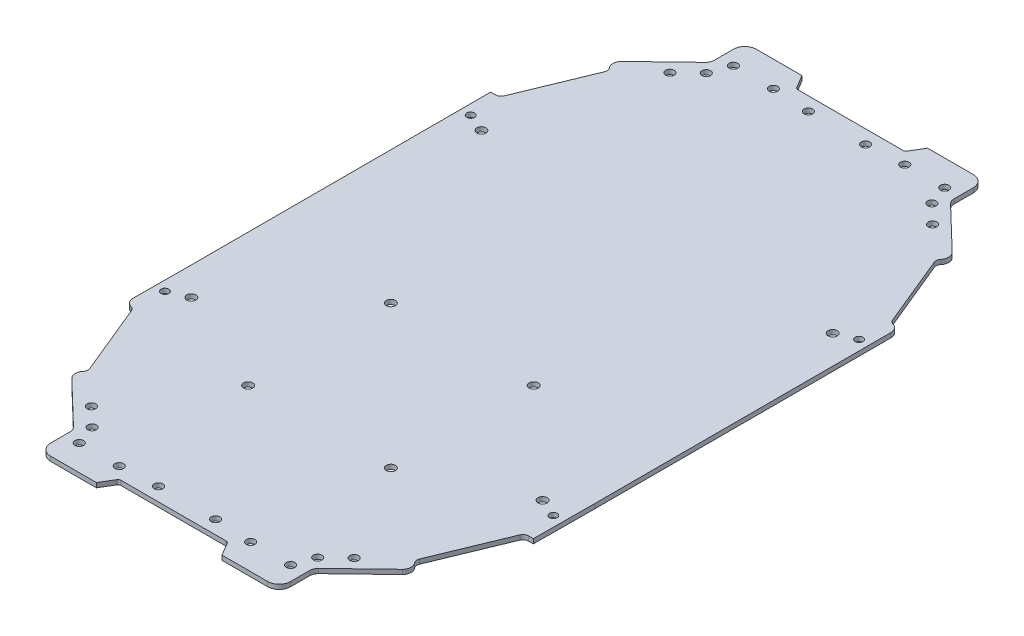
from build123d import *

# Parameters (mm, degrees)
SKETCH1_R        = 1.5
SKETCH1_R_2      = 1.600010398
SKETCH1_R_3      = 1.6
SKETCH1_R_4      = 1.35
EXTRUSION1_DEPTH = 1.6
FILLET1_R        = 1
FILLET2_R        = 4
FILLET3_R        = 3
FILLET4_R        = 3
FILLET5_R        = 2
FILLET6_R        = 2
FILLET7_R        = 3
FILLET8_R        = 3
FILLET9_R        = 2
FILLET10_R       = 2
FILLET11_R       = 3


with BuildPart() as part:
    # Sketch1 → Extrusion1 (new body)
    with BuildSketch(Plane(origin=(0, 0, 0), x_dir=(-1, 0, 0), z_dir=(0, 1, 0))):
        Polygon((59.775158519, 259.059874387), (56.775158519, 264.05987395), (36.775158519, 264.05987395), (36.775158519, 252.05987395), (18.755330752, 234.731117294), (21.527931817, 231.847944851), (10.275158581, 204.559863083), (7.271137723, 204.559863083), (7.157131709, 183.059873956), (7.157131709, 76.612413837), (10.15713177, 76.612413837), (21.409905007, 49.324332069), (18.637303942, 46.441159626), (36.657131709, 29.11240297), (36.657131709, 17.11240297), (56.657131709, 17.11240297), (59.657131709, 22.112402533), (78.657131709, 22.112402533), (97.657131709, 22.112402533), (100.657131709, 17.11240297), (120.657131709, 17.11240297), (120.657131709, 29.11240297), (138.676959475, 46.441159626), (135.90435841, 49.324332069), (147.157131647, 76.612413837), (150.157131709, 76.612413837), (150.157131709, 183.059873956), (150.275158519, 204.559863083), (147.275158457, 204.559863083), (136.022385221, 231.847944851), (138.794986286, 234.731117294), (120.775158519, 252.05987395), (120.775158519, 264.05987395), (100.775158519, 264.05987395), (97.775158519, 259.059874387), (78.657131709, 259.059874387), align=None)
        with Locations((55.657131647, 26.112401639)):
            Circle(SKETCH1_R, mode=Mode.SUBTRACT)
        with Locations((39.157131647, 33.112413837)):
            Circle(SKETCH1_R, mode=Mode.SUBTRACT)
        with Locations((53.657131709, 208.059873956)):
            Circle(SKETCH1_R_2, mode=Mode.SUBTRACT)
        with Locations((53.657131709, 158.059873956)):
            Circle(SKETCH1_R_2, mode=Mode.SUBTRACT)
        with Locations((17.157131647, 89.862401639)):
            Circle(SKETCH1_R_3, mode=Mode.SUBTRACT)
        with Locations((103.657131709, 158.059873956)):
            Circle(SKETCH1_R_2, mode=Mode.SUBTRACT)
        with Locations((41.775158457, 255.059863083)):
            Circle(SKETCH1_R, mode=Mode.SUBTRACT)
        with Locations((39.275158457, 248.059863083)):
            Circle(SKETCH1_R, mode=Mode.SUBTRACT)
        with Locations((10.775158457, 194.05987528)):
            Circle(SKETCH1_R_4, mode=Mode.SUBTRACT)
        with Locations((88.65713177, 26.862413837)):
            Circle(SKETCH1_R, mode=Mode.SUBTRACT)
        with Locations((115.65713177, 26.112413837)):
            Circle(SKETCH1_R, mode=Mode.SUBTRACT)
        with Locations((118.15713177, 33.112413837)):
            Circle(SKETCH1_R, mode=Mode.SUBTRACT)
        with Locations((140.15713177, 89.862401639)):
            Circle(SKETCH1_R_3, mode=Mode.SUBTRACT)
        with Locations((115.775158581, 255.059863083)):
            Circle(SKETCH1_R, mode=Mode.SUBTRACT)
        with Locations((88.775158581, 254.309863083)):
            Circle(SKETCH1_R, mode=Mode.SUBTRACT)
        with Locations((140.275158581, 191.30987528)):
            Circle(SKETCH1_R_3, mode=Mode.SUBTRACT)
        with Locations((146.775158581, 194.05987528)):
            Circle(SKETCH1_R_4, mode=Mode.SUBTRACT)
        with Locations((101.775158581, 255.05987528)):
            Circle(SKETCH1_R, mode=Mode.SUBTRACT)
        with Locations((118.275158581, 248.059863083)):
            Circle(SKETCH1_R, mode=Mode.SUBTRACT)
        with Locations((146.65713177, 87.112401639)):
            Circle(SKETCH1_R_4, mode=Mode.SUBTRACT)
        with Locations((101.65713177, 26.112401639)):
            Circle(SKETCH1_R, mode=Mode.SUBTRACT)
        with Locations((17.275158457, 191.30987528)):
            Circle(SKETCH1_R_3, mode=Mode.SUBTRACT)
        with Locations((55.775158457, 255.05987528)):
            Circle(SKETCH1_R, mode=Mode.SUBTRACT)
        with Locations((68.775158457, 254.309863083)):
            Circle(SKETCH1_R, mode=Mode.SUBTRACT)
        with Locations((10.657131647, 87.112401639)):
            Circle(SKETCH1_R_4, mode=Mode.SUBTRACT)
        with Locations((68.657131647, 26.862413837)):
            Circle(SKETCH1_R, mode=Mode.SUBTRACT)
        with Locations((41.657131647, 26.112413837)):
            Circle(SKETCH1_R, mode=Mode.SUBTRACT)
        with Locations((32.657131647, 39.362413837)):
            Circle(SKETCH1_R, mode=Mode.SUBTRACT)
        with Locations((124.775158581, 241.809863083)):
            Circle(SKETCH1_R, mode=Mode.SUBTRACT)
        with Locations((32.775158457, 241.809863083)):
            Circle(SKETCH1_R, mode=Mode.SUBTRACT)
        with Locations((103.657131709, 208.059873956)):
            Circle(SKETCH1_R_2, mode=Mode.SUBTRACT)
        with Locations((124.65713177, 39.362413837)):
            Circle(SKETCH1_R, mode=Mode.SUBTRACT)
    extrude(amount=EXTRUSION1_DEPTH)

    # Fillet1
    fillet1_edges = [part.edges().sort_by_distance(p)[0] for p in [
        (-97.775158519, 0.8, 259.059874387),
        (-97.657131709, 0.8, 22.112402533),
        (-59.657131709, 0.8, 22.112402533),
        (-59.775158519, 0.8, 259.059874387),
    ]]
    fillet(fillet1_edges, radius=FILLET1_R)

    # Fillet2
    fillet2_edges = [part.edges().sort_by_distance(p)[0] for p in [
        (-120.775158519, 0.8, 264.05987395),
        (-120.657131709, 0.8, 17.11240297),
        (-36.657131709, 0.8, 17.11240297),
        (-36.775158519, 0.8, 264.05987395),
    ]]
    fillet(fillet2_edges, radius=FILLET2_R)

    # Fillet3
    fillet3_edges = [part.edges().sort_by_distance(p)[0] for p in [
        (-120.775158519, 0.8, 252.05987395),
        (-120.657131709, 0.8, 29.11240297),
        (-36.657131709, 0.8, 29.11240297),
        (-36.775158519, 0.8, 252.05987395),
    ]]
    fillet(fillet3_edges, radius=FILLET3_R)

    # Fillet4
    fillet4_edges = [part.edges().sort_by_distance(p)[0] for p in [
        (-138.794986286, 0.8, 234.731117294),
    ]]
    fillet(fillet4_edges, radius=FILLET4_R)

    # Fillet5
    fillet5_edges = [part.edges().sort_by_distance(p)[0] for p in [
        (-136.022385221, 0.8, 231.847944851),
    ]]
    fillet(fillet5_edges, radius=FILLET5_R)

    # Fillet6
    fillet6_edges = [part.edges().sort_by_distance(p)[0] for p in [
        (-21.527931817, 0.8, 231.847944851),
    ]]
    fillet(fillet6_edges, radius=FILLET6_R)

    # Fillet7
    fillet7_edges = [part.edges().sort_by_distance(p)[0] for p in [
        (-18.755330752, 0.8, 234.731117294),
    ]]
    fillet(fillet7_edges, radius=FILLET7_R)

    # Fillet8
    fillet8_edges = [part.edges().sort_by_distance(p)[0] for p in [
        (-138.676959475, 0.8, 46.441159626),
        (-18.637303942, 0.8, 46.441159626),
    ]]
    fillet(fillet8_edges, radius=FILLET8_R)

    # Fillet9
    fillet9_edges = [part.edges().sort_by_distance(p)[0] for p in [
        (-21.409905007, 0.8, 49.324332069),
        (-135.90435841, 0.8, 49.324332069),
    ]]
    fillet(fillet9_edges, radius=FILLET9_R)

    # Fillet10
    fillet10_edges = [part.edges().sort_by_distance(p)[0] for p in [
        (-147.275158457, 0.8, 204.559863083),
        (-147.157131647, 0.8, 76.612413837),
        (-10.15713177, 0.8, 76.612413837),
        (-10.275158581, 0.8, 204.559863083),
    ]]
    fillet(fillet10_edges, radius=FILLET10_R)

    # Fillet11
    fillet11_edges = [part.edges().sort_by_distance(p)[0] for p in [
        (-150.275158519, 0.8, 204.559863083),
        (-7.157131709, 0.8, 76.612413837),
    ]]
    fillet(fillet11_edges, radius=FILLET11_R)


solid = part.part
